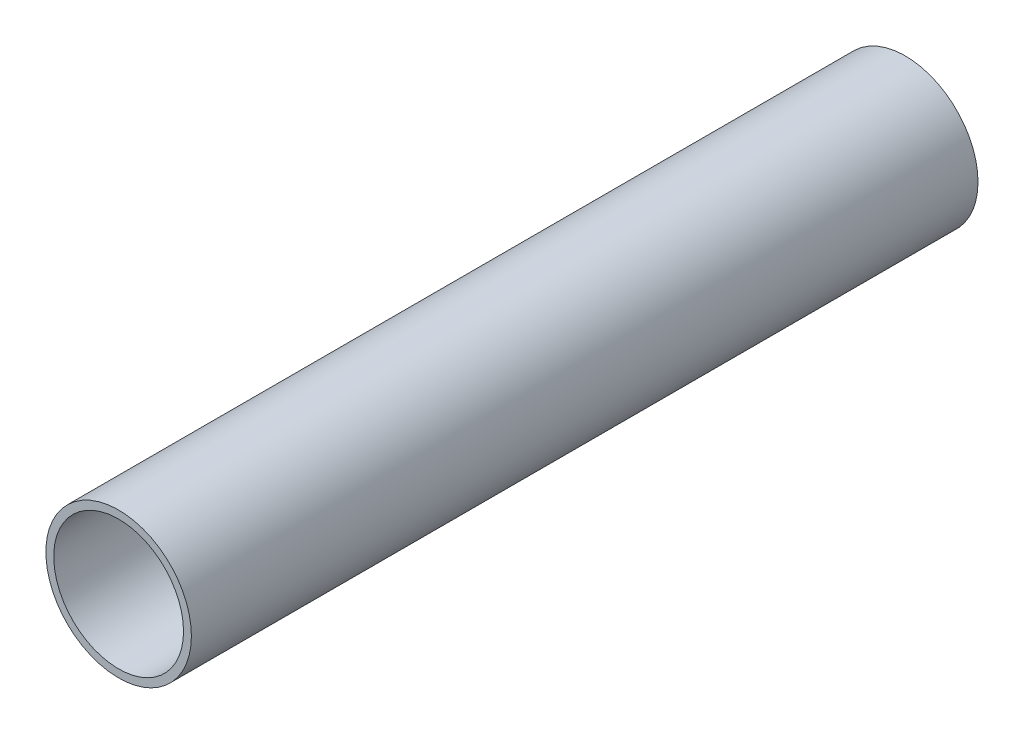
from build123d import *

# Parameters (mm, degrees)
SKETCH2_R           = 23.495
SKETCH2_R_2         = 20.955
BOSS_EXTRUDE1_DEPTH = 254


with BuildPart() as part:
    # Sketch2 → Boss-Extrude1 (new body)
    with BuildSketch(Plane.XY):
        Circle(SKETCH2_R)
        Circle(SKETCH2_R_2, mode=Mode.SUBTRACT)
    extrude(amount=-BOSS_EXTRUDE1_DEPTH)


solid = part.part
